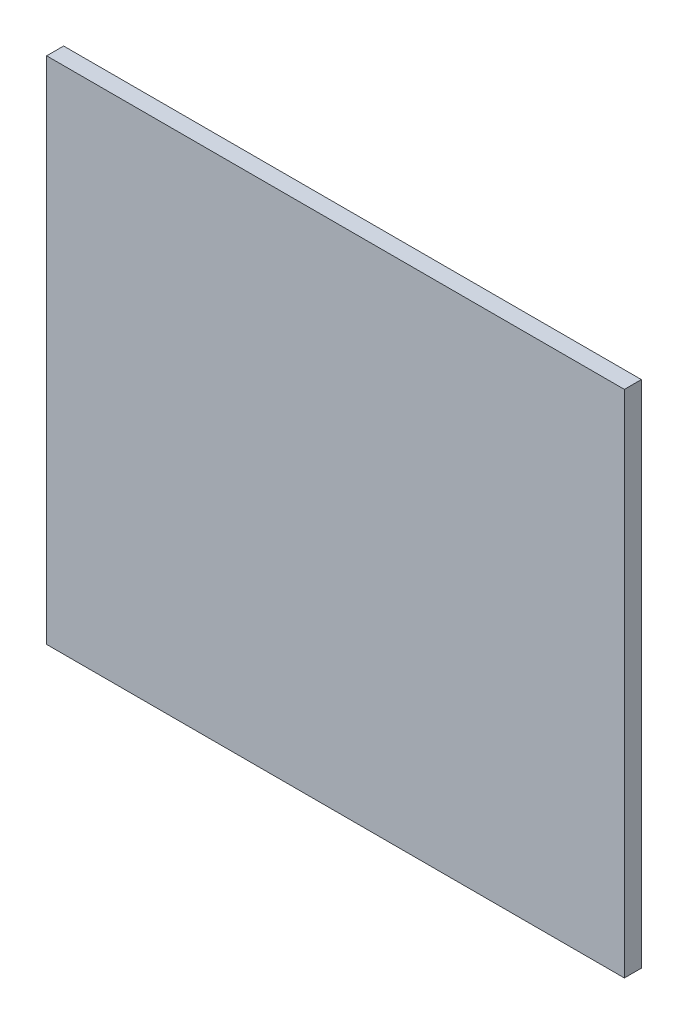
from build123d import *

# Parameters (mm, degrees)
SKETCH2_W           = 170
SKETCH2_H           = 150
BOSS_EXTRUDE1_DEPTH = 5


with BuildPart() as part:
    # Sketch2 → Boss-Extrude1 (new body)
    with BuildSketch(Plane.XY):
        Rectangle(SKETCH2_W, SKETCH2_H)
    extrude(amount=BOSS_EXTRUDE1_DEPTH)


solid = part.part
